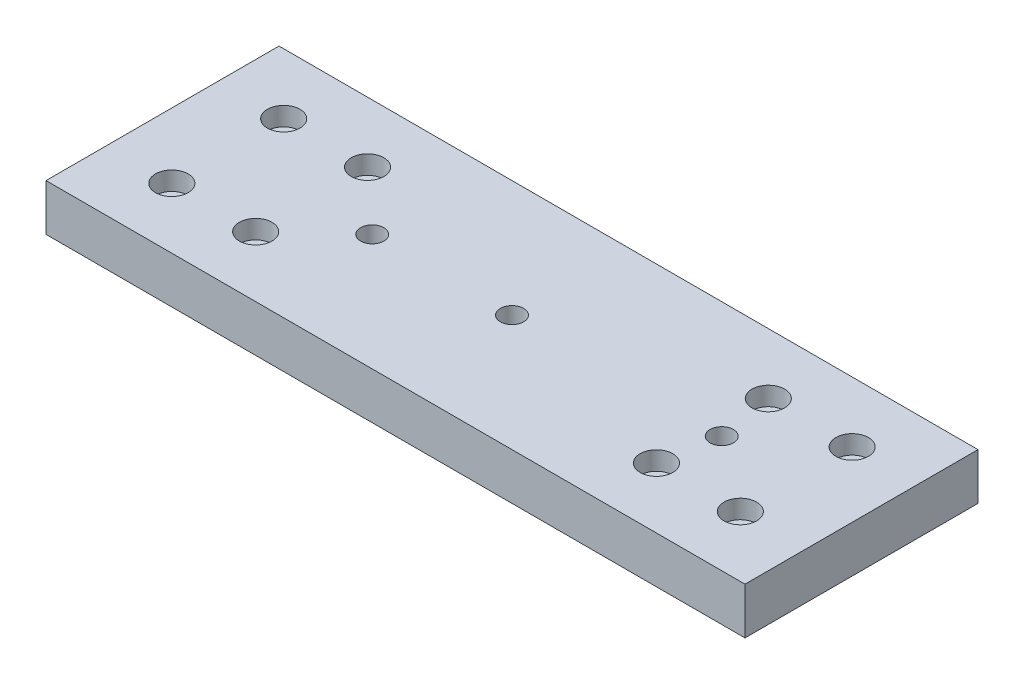
from build123d import *

# Parameters (mm, degrees)
SKETCH1_W                         = 150
SKETCH1_H                         = 50
BOSS_EXTRUDE1_DEPTH               = 10
SKETCH2_R                         = 1.5
LINEAR_BEARING_MOUNT_DEPTH        = 11
SKETCH3_R                         = 2.5
SURFACE_PROFILE_MOUNT_DEPTH       = 11
SKETCH4_R                         = 4.25
SURF_PROF_MOUNT_COUNTERSINK_DEPTH = 5
SKETCH5_R                         = 3.5
CUT_EXTRUDE1_DEPTH                = 4


with BuildPart() as part:
    # Sketch1 → Boss-Extrude1 (new body)
    with BuildSketch(Plane(origin=(0, 0, 0), x_dir=(1, 0, 0), z_dir=(0, 1, 0))):
        Rectangle(SKETCH1_W, SKETCH1_H)
    extrude(amount=BOSS_EXTRUDE1_DEPTH)

    # Sketch2 → Linear_bearing_mount (cut, through all)
    with BuildSketch(Plane(origin=(0, 10, 0), x_dir=(1, 0, 0), z_dir=(0, 1, 0))):
        with Locations((-43, -12)):
            Circle(SKETCH2_R)
        with Locations((-61, -12)):
            Circle(SKETCH2_R)
        with Locations((43, -12)):
            Circle(SKETCH2_R)
        with Locations((61, -12)):
            Circle(SKETCH2_R)
        with Locations((61, 12)):
            Circle(SKETCH2_R)
        with Locations((43, 12)):
            Circle(SKETCH2_R)
        with Locations((-61, 12)):
            Circle(SKETCH2_R)
        with Locations((-43, 12)):
            Circle(SKETCH2_R)
    extrude(amount=-LINEAR_BEARING_MOUNT_DEPTH, mode=Mode.SUBTRACT)

    # Sketch3 → Surface_profile_mount (cut, through all)
    with BuildSketch(Plane.XZ):
        Circle(SKETCH3_R)
        with Locations((45, 0)):
            Circle(SKETCH3_R)
        with Locations((-30, 0)):
            Circle(SKETCH3_R)
    extrude(amount=-SURFACE_PROFILE_MOUNT_DEPTH, mode=Mode.SUBTRACT)

    # Sketch4 → Surf.prof.mount_countersink (cut)
    with BuildSketch(Plane.XZ):
        with Locations((45, 0)):
            Circle(SKETCH4_R)
        Circle(SKETCH4_R)
        with Locations((-30, 0)):
            Circle(SKETCH4_R)
    extrude(amount=-SURF_PROF_MOUNT_COUNTERSINK_DEPTH, mode=Mode.SUBTRACT)

    # Sketch5 → Cut-Extrude1 (cut)
    with BuildSketch(Plane(origin=(0, 10, 0), x_dir=(1, 0, 0), z_dir=(0, 1, 0))):
        with Locations((-61, 12)):
            Circle(SKETCH5_R)
        with Locations((-43, 12)):
            Circle(SKETCH5_R)
        with Locations((-43, -12)):
            Circle(SKETCH5_R)
        with Locations((-61, -12)):
            Circle(SKETCH5_R)
        with Locations((61, -12)):
            Circle(SKETCH5_R)
        with Locations((43, -12)):
            Circle(SKETCH5_R)
        with Locations((43, 12)):
            Circle(SKETCH5_R)
        with Locations((61, 12)):
            Circle(SKETCH5_R)
    extrude(amount=-CUT_EXTRUDE1_DEPTH, mode=Mode.SUBTRACT)


solid = part.part
